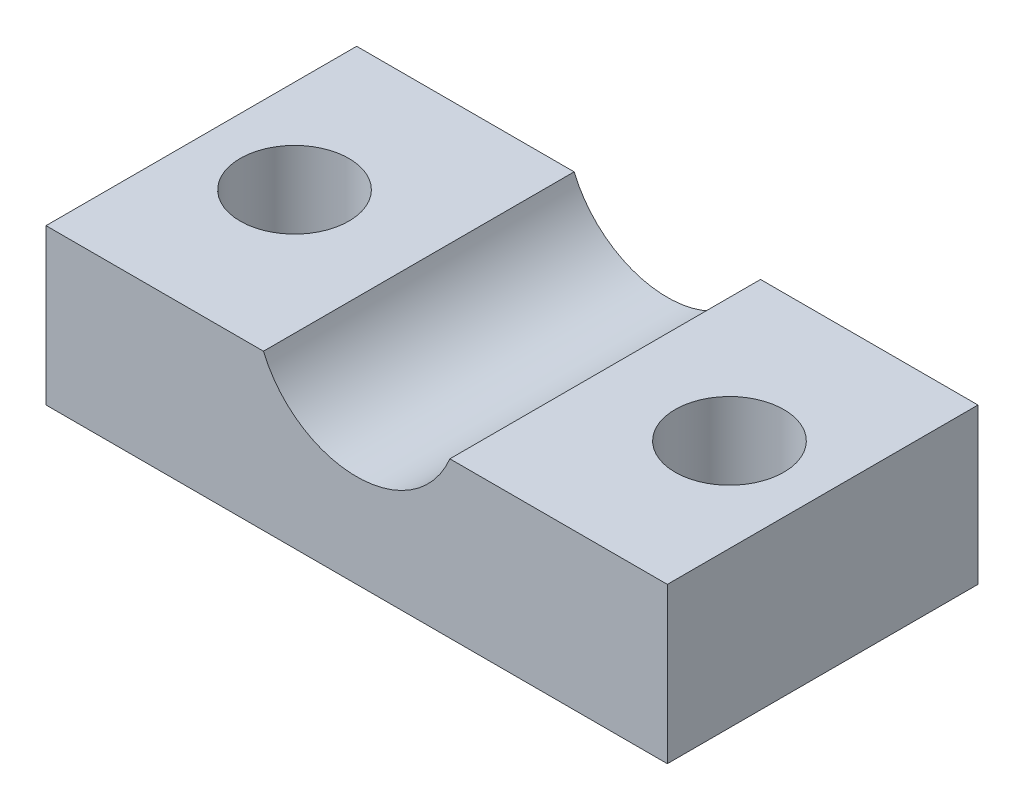
from build123d import *

# Parameters (mm, degrees)
AUFSATZ_LINEAR_AUSTRAGEN1_DEPTH = 10
SKIZZE2_R                       = 1.75
SCHNITT_LINEAR_AUSTRAGEN1_DEPTH = 6


with BuildPart() as part:
    # Skizze1 → Aufsatz-Linear austragen1 (new body)
    with BuildSketch(Plane.XY):
        with BuildLine():
            Line((0, 0), (20, 0))
            Line((20, 0), (20, 5))
            Line((20, 5), (13, 5))
            ThreePointArc((13, 5), (10, 3), (7, 5))
            Line((7, 5), (0, 5))
            Line((0, 5), (0, 0))
        make_face()
    extrude(amount=AUFSATZ_LINEAR_AUSTRAGEN1_DEPTH)

    # Skizze2 → Schnitt-Linear austragen1 (cut, through all)
    with BuildSketch(Plane(origin=(0, 5, 0), x_dir=(1, 0, 0), z_dir=(0, 1, 0))):
        with Locations((3, -5)):
            Circle(SKIZZE2_R)
        with Locations((17, -5)):
            Circle(SKIZZE2_R)
    extrude(amount=-SCHNITT_LINEAR_AUSTRAGEN1_DEPTH, mode=Mode.SUBTRACT)


solid = part.part
